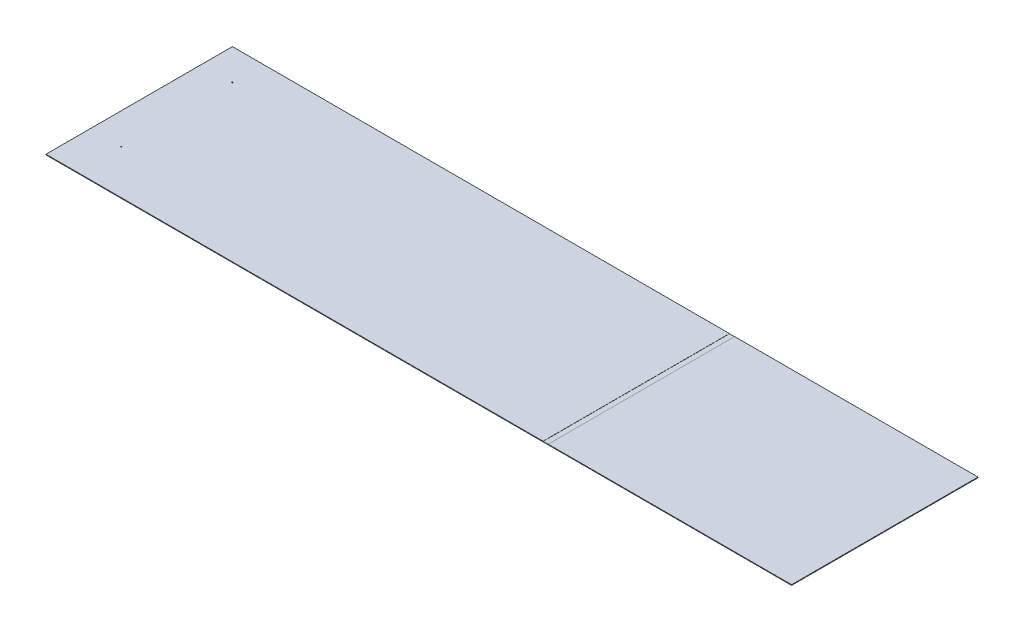
from build123d import *

# Parameters (mm, degrees)
SKETCH1_W           = 3657.6
SKETCH1_H           = 914.4
BOSS_EXTRUDE1_DEPTH = 3.175
SKETCH2_R           = 2.5796875
CUT_EXTRUDE1_DEPTH  = 3.175
SKETCH3_W           = 25.4
SKETCH3_H           = 914.4
CUT_EXTRUDE2_DEPTH  = 0.79375


with BuildPart() as part:
    # Sketch1 → Boss-Extrude1 (new body)
    with BuildSketch(Plane(origin=(0, 0, 0), x_dir=(1, 0, 0), z_dir=(0, 1, 0))):
        with Locations((420.120139697, 346.492665891)):
            Rectangle(SKETCH1_W, SKETCH1_H)
    extrude(amount=BOSS_EXTRUDE1_DEPTH)

    # Sketch2 → Cut-Extrude1 (cut)
    with BuildSketch(Plane(origin=(0, 3.175, 0), x_dir=(1, 0, 0), z_dir=(0, 1, 0))):
        with Locations((-1256.279860303, 651.292665891)):
            Circle(SKETCH2_R)
        with Locations((-1256.279860303, 105.192665891)):
            Circle(SKETCH2_R)
    extrude(amount=-CUT_EXTRUDE1_DEPTH, mode=Mode.SUBTRACT)

    # Sketch3 → Cut-Extrude2 (cut)
    with BuildSketch(Plane(origin=(0, 3.175, 0), x_dir=(1, 0, 0), z_dir=(0, 1, 0))):
        with Locations((1042.420139697, 346.492665891)):
            Rectangle(SKETCH3_W, SKETCH3_H)
    extrude(amount=-CUT_EXTRUDE2_DEPTH, mode=Mode.SUBTRACT)


solid = part.part
